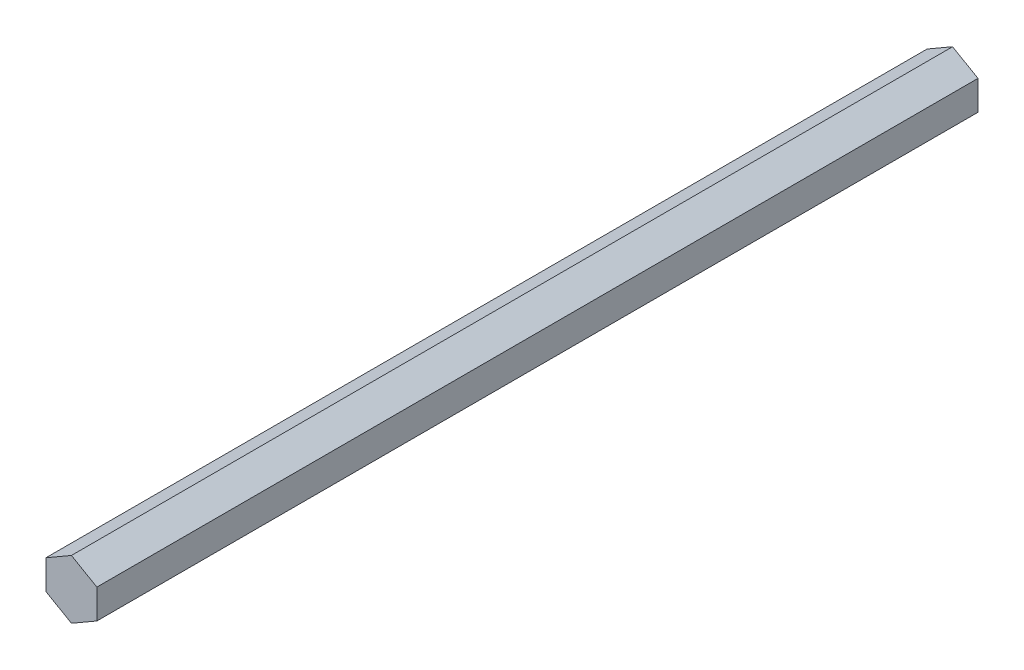
from build123d import *

# Parameters (mm, degrees)
BOSS_EXTRUDE1_DEPTH = 220


with BuildPart() as part:
    # Sketch1 → Boss-Extrude1 (new body)
    with BuildSketch(Plane.XY):
        Polygon((0, 7.332348419), (-6.35, 3.666174209), (-6.35, -3.666174209), (0, -7.332348419), (6.35, -3.666174209), (6.35, 3.666174209), align=None)
    extrude(amount=BOSS_EXTRUDE1_DEPTH)


solid = part.part
